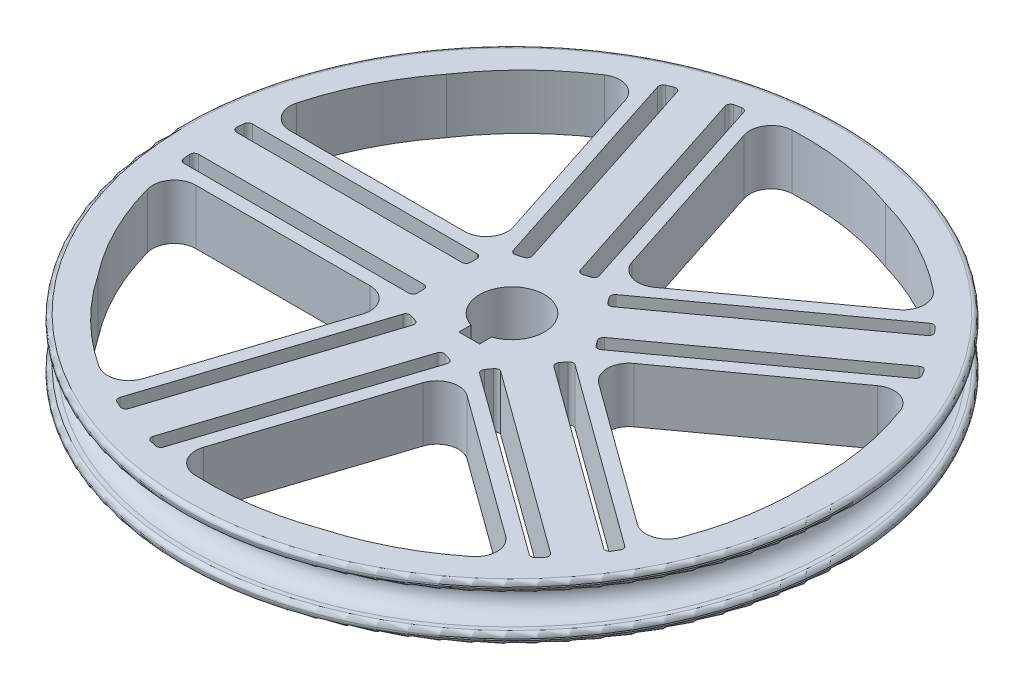
from build123d import *

# Parameters (mm, degrees)
SKETCH2_R          = 7.500000000000012
CUT_EXTRUDE3_DEPTH = 170.07953750392153
CUT_EXTRUDE5_DEPTH = 170.07953750392153
CUT_EXTRUDE7_DEPTH = 170.07953750392153
CIRPATTERN1_COUNT  = 5
FILLET1_R          = 5
FILLET2_R          = 5
FILLET3_R          = 1


with BuildPart() as part:
    # Sketch1 → Revolve2 (revolve)
    with BuildSketch(Plane.XY, mode=Mode.PRIVATE) as revolve2_sk:
        with BuildLine():
            Line((-4.3e-16, 8), (-1.0000000000000004, 8))
            ThreePointArc((-1.0000000000000004, 8), (-1.7071067811865492, 8.292893218813454), (-2.0000000000000004, 9.000000000000002))
            Line((-2.0000000000000004, 9.000000000000002), (-1.9999999999999996, 9.350000000000001))
            ThreePointArc((-1.9999999999999996, 9.350000000000001), (-1.7071067811865472, 10.057106781186548), (-1.0000000000000004, 10.350000000000001))
            Line((-1.0000000000000004, 10.350000000000001), (74.2, 10.35))
            Line((74.2, 10.35), (74.2, -2.3499999999999996))
            Line((74.2, -2.3499999999999996), (-1.0000000000000004, -2.3500000000000014))
            ThreePointArc((-1.0000000000000004, -2.3500000000000014), (-1.7071067811865475, -2.0571067811865476), (-1.9999999999999996, -1.3500000000000005))
            Line((-1.9999999999999996, -1.3500000000000005), (-2.0000000000000004, -1))
            ThreePointArc((-2.0000000000000004, -1), (-1.707106781186548, -0.2928932188134522), (-1.0000000000000002, 2.2e-16))
            Line((-1.0000000000000002, 2.2e-16), (0, 0))
            ThreePointArc((0, 0), (4.000000027037184, 4), (-4.3e-16, 8))
        make_face()
    revolve(revolve2_sk.sketch.rotate(Axis((74.2, 10.35, 0), (0, -1, 0)), 270), axis=Axis((74.2, 10.35, 0), (0, -1, 0)))

    # Sketch2 → Cut-Extrude3 (cut, through all)
    with BuildSketch(Plane.XZ.offset(2.35)):
        with Locations((74.2, 0)):
            Circle(SKETCH2_R)
    extrude(amount=-CUT_EXTRUDE3_DEPTH, mode=Mode.SUBTRACT)

    # Sketch5 → Cut-Extrude5 (cut, through all)
    with BuildSketch(Plane.XZ.offset(2.35)):
        with BuildLine():
            ThreePointArc((71.80999999999983, 7.109001336334053), (72.98911396541733, 7.401604894295077), (74.2, 7.500000000000012))
            Line((74.2, 7.500000000000007), (74.2, 9.890000000000006))
            Line((74.2, 9.890000000000006), (71.81, 9.890000000000006))
            Line((71.81, 9.890000000000006), (71.81, 7.109001336334006))
        make_face()
        with BuildLine():
            Line((74.2, 9.890000000000006), (74.2, 7.500000000000007))
            ThreePointArc((74.2, 7.500000000000012), (75.41088603458262, 7.401604894295087), (76.59000000000006, 7.1090013363340905))
            Line((76.59, 7.109001336334073), (76.59, 9.890000000000006))
            Line((76.59, 9.890000000000006), (74.2, 9.890000000000006))
        make_face()
        with BuildLine():
            Line((74.2, 6.693565352915491), (74.2, 7.500000000000007))
            ThreePointArc((74.2, 7.500000000000012), (72.98911396541733, 7.401604894295077), (71.80999999999983, 7.109001336334053))
            Line((71.81, 7.109001336334006), (71.81, 6.693565352915491))
            Line((71.81, 6.693565352915491), (74.2, 6.693565352915491))
        make_face()
        with BuildLine():
            ThreePointArc((76.59000000000006, 7.1090013363340905), (75.41088603458262, 7.401604894295087), (74.2, 7.500000000000012))
            Line((74.2, 7.500000000000007), (74.2, 6.693565352915491))
            Line((74.2, 6.693565352915491), (76.59, 6.693565352915491))
            Line((76.59, 6.693565352915491), (76.59, 7.109001336334073))
        make_face()
    extrude(amount=-CUT_EXTRUDE5_DEPTH, mode=Mode.SUBTRACT)

    # Sketch3 → Cut-Extrude7 (cut, symmetric)
    with BuildSketch(Plane.XZ.offset(2.35)):
        with BuildLine():
            Line((95.38033988749895, 65.18638338353188), (79.92949016875157, 17.633557568774194))
            Line((79.92949016875157, 17.633557568774194), (123.13574516852024, 49.024739301950376))
            ThreePointArc((123.13574516852026, 49.02473930195039), (110.26479461810771, 58.83451986559545), (95.38033988749895, 65.18638338353188))
        make_face()
        with BuildLine():
            Line((81.692845925629, 15.206506585649347), (83.75009430865265, 12.374947105337036))
            Line((83.75009430865265, 12.37494710533703), (127.57586700245766, 44.21623479008217))
            ThreePointArc((127.57586700245767, 44.21623479008218), (126.43132133107116, 45.55053484950059), (125.2513534655746, 46.85361476986195))
            Line((125.25135346557457, 46.85361476986195), (81.692845925629, 15.206506585649343))
        make_face()
        with BuildLine():
            Line((88.92041552259576, 5.2586104634371535), (90.97766390561942, 2.4270509831248446))
            Line((90.97766390561941, 2.427050983124836), (134.53617144556497, 34.07415916733744))
            ThreePointArc((134.536171445565, 34.074159167337456), (133.66149891930684, 35.599049135257125), (132.74618821640075, 37.09989814818232))
            Line((132.74618821640072, 37.0998981481823), (88.92041552259577, 5.258610463437156))
        make_face()
        with BuildLine():
            Line((135.9472746622656, 31.391181733176005), (92.74101966249684, 0))
            Line((92.74101966249684, 0), (142.74101966249685, 0))
            ThreePointArc((142.74101966249685, -3.55e-15), (141.29958793690867, 16.118791436038173), (135.94727466226564, 31.39118173317601))
        make_face()
    cut_extrude7 = extrude(amount=CUT_EXTRUDE7_DEPTH, both=True, mode=Mode.SUBTRACT)

    # CirPattern1: Cut-Extrude7 ×5 about axis
    cirpattern1_axis = Axis((74.20000000000005, 0, 1.955e-14), (0, 1, 0))
    for i in range(1, CIRPATTERN1_COUNT):
        add(cut_extrude7.rotate(cirpattern1_axis, i * 360 / CIRPATTERN1_COUNT), mode=Mode.SUBTRACT)

    # Fillet1
    fillet1_edges = [part.edges().sort_by_distance(p)[0] for p in [
        (79.92949016875158, 4, -17.633557568774165),
        (59.20000000000006, 4, -10.898137920080366),
        (59.20000000000009, 4, 10.898137920080437),
        (92.74101966249687, 4, 0),
        (79.9294901687516, 4, 17.633557568774194),
    ]]
    fillet(fillet1_edges, radius=FILLET1_R)

    # Fillet2
    fillet2_edges = [part.edges().sort_by_distance(p)[0] for p in [
        (63.42616928543508, 4, -68.42555656007806),
        (123.13574516852012, 4, -49.024739301950504),
        (63.42616928543528, 4, 68.42555656007814),
        (5.794131767095848, 4, -10.898137920080387),
        (42.69667911668331, 4, -61.6901369113842),
        (135.94727466226553, 4, -31.391181733176182),
        (42.6966791166835, 4, 61.69013691138433),
        (5.794131767095877, 4, 10.898137920080636),
        (135.94727466226564, 4, 31.391181733176005),
        (123.13574516852029, 4, 49.02473930195038),
    ]]
    fillet(fillet2_edges, radius=FILLET2_R)

    # Fillet3
    fillet3_edges = [part.edges().sort_by_distance(p)[0] for p in [
        (5.358723682190231, 4, -7.898137920080352),
        (5.028365784003142, 4, -4.398137920080174),
        (59.20000000000009, 4, -4.398137920080387),
        (59.20000000000009, 4, -7.89813792008038),
        (5.028365784003199, 4, 4.398137920080622),
        (5.358723682190231, 4, 7.898137920080458),
        (59.2000000000001, 4, 7.89813792008043),
        (59.2000000000001, 4, 4.398137920080437),
        (57.007667227026886, 4, 67.14523282481842),
        (60.43845123882554, 4, 67.91260327335034),
        (77.07632061986617, 4, 16.706506585649336),
        (73.74762281283313, 4, 15.624947105337029),
        (45.4153001678449, 4, 63.03128559090625),
        (48.641911770112316, 4, 64.427034102999),
        (65.38186735591856, 4, 12.906748383517566),
        (62.05316954888552, 4, 11.825188903205259),
        (127.57586700245741, 4, -44.21623479008247),
        (125.25135346557457, 4, -46.85361476986196),
        (81.692845925629, 4, -15.206506585649308),
        (83.75009430865266, 4, -12.374947105337),
        (134.536171445565, 4, -34.074159167337456),
        (132.74618821640055, 4, -37.09989814818263),
        (88.92041552259579, 4, -5.2586104634371225),
        (90.97766390561944, 4, -2.427050983124815),
        (48.641911770111946, 4, -64.42703410299882),
        (45.41530016784486, 4, -63.03128559090621),
        (62.053169548885535, 4, -11.825188903205202),
        (65.38186735591856, 4, -12.906748383517517),
        (60.43845123882551, 4, -67.9126032733503),
        (57.0076672270265, 4, -67.14523282481832),
        (73.74762281283314, 4, -15.624947105336986),
        (77.07632061986617, 4, -16.7065065856493),
        (132.74618821640078, 4, 37.099898148182305),
        (134.53617144556503, 4, 34.07415916733745),
        (90.97766390561944, 4, 2.4270509831248406),
        (88.92041552259579, 4, 5.258610463437154),
        (125.25135346557461, 4, 46.85361476986195),
        (127.5758670024577, 4, 44.21623479008218),
        (83.75009430865268, 4, 12.374947105337032),
        (81.69284592562903, 4, 15.206506585649345),
    ]]
    fillet(fillet3_edges, radius=FILLET3_R)


solid = part.part
